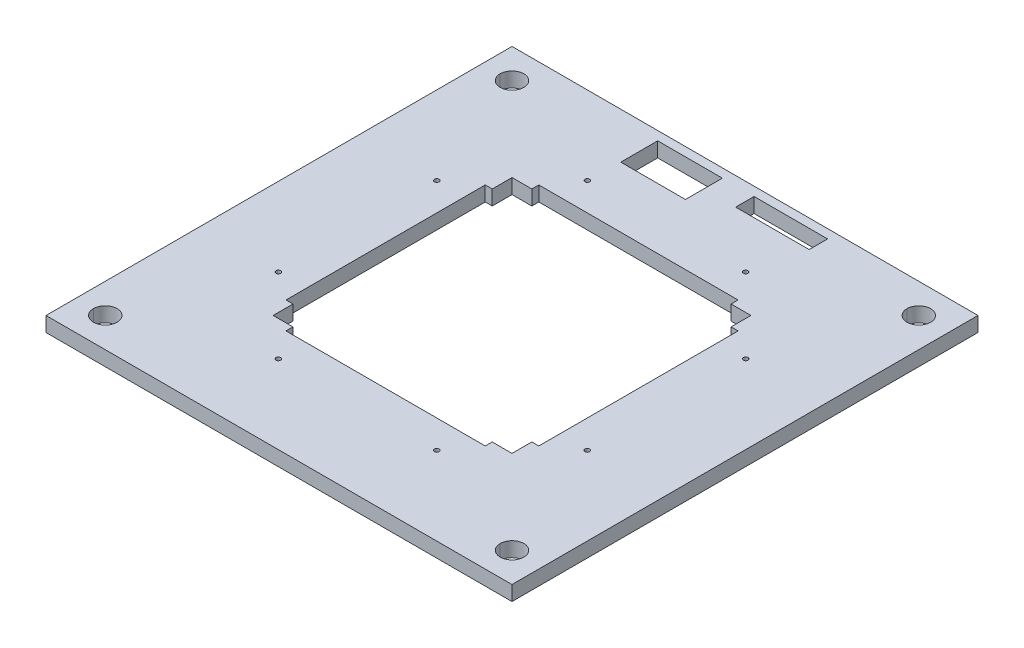
from build123d import *

# Parameters (mm, degrees)
SKETCH1_W           = 200.025
SKETCH1_H           = 200.025
SKETCH1_R           = 5.08
SKETCH1_W_2         = 27.758924323
SKETCH1_H_2         = 15.850492031
SKETCH1_W_3         = 31.563171913
SKETCH1_H_3         = 7.913427648
BOSS_EXTRUDE1_DEPTH = 6.35
SKETCH2_W           = 200.025
SKETCH2_H           = 200.025
SKETCH2_R           = 5.08
SKETCH2_W_2         = 149.225
SKETCH2_H_2         = 149.225
SKETCH2_W_3         = 27.758924323
SKETCH2_H_3         = 15.874128766
SKETCH2_W_4         = 31.563171913
SKETCH2_H_4         = 7.937064383
BOSS_EXTRUDE2_DEPTH = 6.350254
SKETCH3_R           = 1.00000054
CUT_EXTRUDE1_DEPTH  = 23.622


with BuildPart() as part:
    # Sketch1 → Boss-Extrude1 (new body)
    with BuildSketch(Plane(origin=(0, 0, 0), x_dir=(1, 0, 0), z_dir=(0, 1, 0))):
        with Locations((0, -0.023636735)):
            Rectangle(SKETCH1_W, SKETCH1_H)
        with Locations((-87.3125, 87.288863265)):
            Circle(SKETCH1_R, mode=Mode.SUBTRACT)
        with Locations((87.3125, 87.288863265)):
            Circle(SKETCH1_R, mode=Mode.SUBTRACT)
        with Locations((-87.3125, -87.288863265)):
            Circle(SKETCH1_R, mode=Mode.SUBTRACT)
        with Locations((87.3125, -87.288863265)):
            Circle(SKETCH1_R, mode=Mode.SUBTRACT)
        Polygon((38.5, 54.27), (42.77, 54.27), (42.77, 51.27), (49, 51.27), (51.27, 51.27), (51.27, 49), (51.27, 42.77), (54.27, 42.77), (54.27, 38.5), (54.27, -38.5), (54.27, -42.77), (51.27, -42.77), (51.27, -49), (51.27, -51.293636735), (48.998814015, -51.293636735), (42.77, -51.270990058), (42.77, -54.27), (38.5, -54.27), (-38.5, -54.27), (-42.77, -54.27), (-42.77, -51.270990058), (-48.998814015, -51.293636735), (-51.27, -51.293636735), (-51.27, -49), (-51.27, -42.77), (-54.27, -42.77), (-54.27, -38.5), (-54.27, 38.5), (-54.27, 42.77), (-51.27, 42.77), (-51.27, 49), (-51.27, 51.27), (-49, 51.27), (-42.77, 51.27), (-42.77, 54.27), (-38.5, 54.27), align=None, mode=Mode.SUBTRACT)
        with Locations((-19.766444167, 88.253617249)):
            Rectangle(SKETCH1_W_2, SKETCH1_H_2, mode=Mode.SUBTRACT)
        with Locations((23.505506165, 92.222149441)):
            Rectangle(SKETCH1_W_3, SKETCH1_H_3, mode=Mode.SUBTRACT)
    extrude(amount=BOSS_EXTRUDE1_DEPTH)

    # Sketch2 → Boss-Extrude2 (add)
    with BuildSketch(Plane(origin=(0, 6.35, 0), x_dir=(1, 0, 0), z_dir=(0, 1, 0))):
        Rectangle(SKETCH2_W, SKETCH2_H)
        with Locations((-87.3125, 87.3125)):
            Circle(SKETCH2_R, mode=Mode.SUBTRACT)
        with Locations((87.3125, 87.3125)):
            Circle(SKETCH2_R, mode=Mode.SUBTRACT)
        with Locations((-87.3125, -87.3125)):
            Circle(SKETCH2_R, mode=Mode.SUBTRACT)
        with Locations((87.3125, -87.3125)):
            Circle(SKETCH2_R, mode=Mode.SUBTRACT)
        Rectangle(SKETCH2_W_2, SKETCH2_H_2, mode=Mode.SUBTRACT)
        with Locations((-19.766444167, 88.265435617)):
            Rectangle(SKETCH2_W_3, SKETCH2_H_3, mode=Mode.SUBTRACT)
        with Locations((23.505506165, 92.233967809)):
            Rectangle(SKETCH2_W_4, SKETCH2_H_4, mode=Mode.SUBTRACT)
    extrude(amount=-BOSS_EXTRUDE2_DEPTH)

    # Sketch3 → Cut-Extrude1 (cut)
    with BuildSketch(Plane.XZ):
        with Locations((-33.999932, -66.312542)):
            Circle(SKETCH3_R)
        with Locations((33.999932, -66.312542)):
            Circle(SKETCH3_R)
        with Locations((-66.312542, 33.999932)):
            Circle(SKETCH3_R)
        with Locations((-66.312542, -33.999932)):
            Circle(SKETCH3_R)
        with Locations((33.999932, 66.312542)):
            Circle(SKETCH3_R)
        with Locations((-33.999932, 66.312542)):
            Circle(SKETCH3_R)
        with Locations((66.312542, -33.999932)):
            Circle(SKETCH3_R)
        with Locations((66.312542, 33.999932)):
            Circle(SKETCH3_R)
    extrude(amount=-CUT_EXTRUDE1_DEPTH, mode=Mode.SUBTRACT)


solid = part.part
